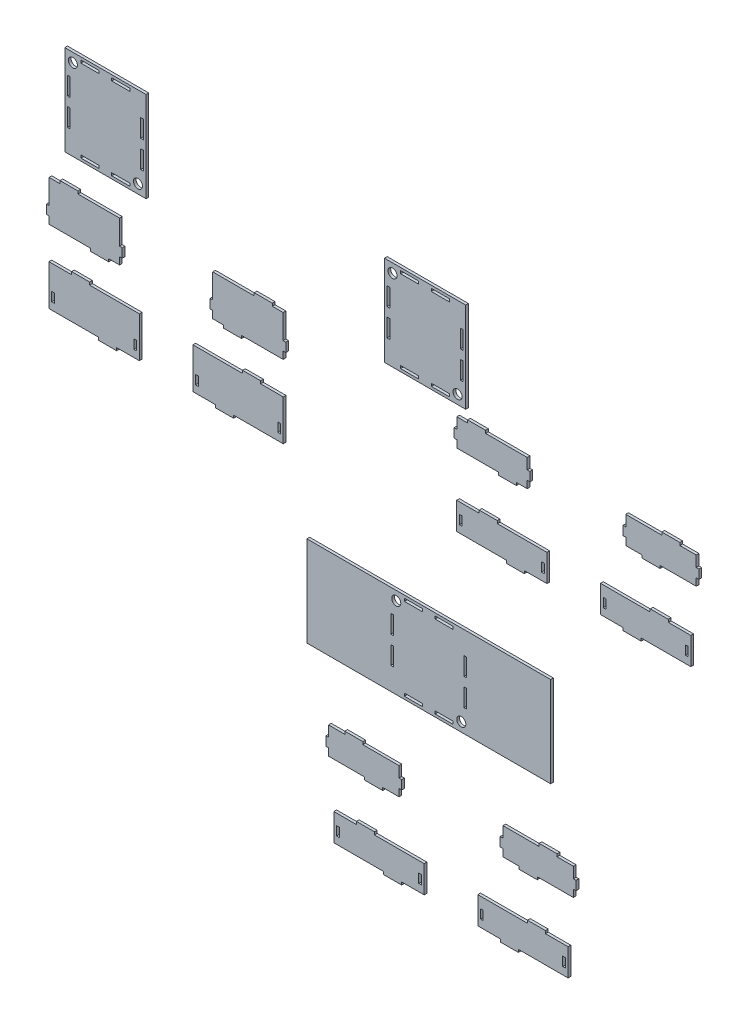
from build123d import *

# Parameters (mm, degrees)
EXTRUDE_1_DEPTH    = 3
SKETCH_1_W         = 3
SKETCH_1_H         = 10
EXTRUDE_1_2_DEPTH  = 3
EXTRUDE_1_3_DEPTH  = 3
SKETCH_1_W_2       = 90
SKETCH_1_H_2       = 100
SKETCH_1_R         = 5
SKETCH_1_H_3       = 20
SKETCH_1_W_3       = 20
SKETCH_1_H_4       = 3
EXTRUDE_1_4_DEPTH  = 3
EXTRUDE_1_5_DEPTH  = 3
EXTRUDE_1_6_DEPTH  = 3
EXTRUDE_1_7_DEPTH  = 3
EXTRUDE_1_8_DEPTH  = 3
EXTRUDE_1_9_DEPTH  = 3
EXTRUDE_1_10_DEPTH = 3
EXTRUDE_1_11_DEPTH = 3
EXTRUDE_1_12_DEPTH = 3
EXTRUDE_1_13_DEPTH = 3
EXTRUDE_1_14_DEPTH = 3
EXTRUDE_1_15_DEPTH = 3


with BuildPart() as part:
    # Эскиз1 → Бобышка-Вытянуть1 (new body)
    with BuildSketch(Plane.XY):
        Polygon((-251.165470976, 199.705049255), (-254.165470976, 199.705049255), (-254.165470976, 189.705049255), (-251.165470976, 189.705049255), (-251.165470976, 181.705049255), (-205.165470976, 181.705049255), (-205.165470976, 178.705049255), (-185.165470976, 178.705049255), (-185.165470976, 181.705049255), (-173.165470976, 181.705049255), (-173.165470976, 189.705049255), (-170.165470976, 189.705049255), (-170.165470976, 199.705049255), (-173.165470976, 199.705049255), (-173.165470976, 226.705049255), (-219.165470976, 226.705049255), (-219.165470976, 229.705049255), (-239.165470976, 229.705049255), (-239.165470976, 226.705049255), (-251.165470976, 226.705049255), align=None)
    extrude(amount=EXTRUDE_1_DEPTH)


with BuildPart() as body_2:
    # Эскиз1 → Extrude 1 2 (new body)
    with BuildSketch(Plane.XY):
        Polygon((-196.271811444, 100.833532478), (-196.271811444, 97.833532478), (-176.271811444, 97.833532478), (-176.271811444, 100.833532478), (-151.271811444, 100.833532478), (-151.271811444, 145.833532478), (-206.271811444, 145.833532478), (-206.271811444, 148.833532478), (-226.271811444, 148.833532478), (-226.271811444, 145.833532478), (-251.271811444, 145.833532478), (-251.271811444, 100.833532478), align=None)
        with Locations((-246.771811444, 113.833532478)):
            Rectangle(SKETCH_1_W, SKETCH_1_H, mode=Mode.SUBTRACT)
        with Locations((-155.771811444, 113.833532478)):
            Rectangle(SKETCH_1_W, SKETCH_1_H, mode=Mode.SUBTRACT)
    extrude(amount=EXTRUDE_1_2_DEPTH)


with BuildPart() as body_3:
    # Эскиз1 → Extrude 1 3 (new body)
    with BuildSketch(Plane.XY):
        Polygon((-58.028496911, 181.705049255), (-70.028496911, 181.705049255), (-70.028496911, 189.705049255), (-73.028496911, 189.705049255), (-73.028496911, 199.705049255), (-70.028496911, 199.705049255), (-70.028496911, 226.705049255), (-24.028496911, 226.705049255), (-24.028496911, 229.705049255), (-4.028496911, 229.705049255), (-4.028496911, 226.705049255), (7.971503089, 226.705049255), (7.971503089, 199.705049255), (10.971503089, 199.705049255), (10.971503089, 189.705049255), (7.971503089, 189.705049255), (7.971503089, 181.705049255), (-38.028496911, 181.705049255), (-38.028496911, 178.705049255), (-58.028496911, 178.705049255), align=None)
    extrude(amount=EXTRUDE_1_3_DEPTH)


with BuildPart() as body_4:
    # Эскиз1 → Extrude 1 4 (new body)
    with BuildSketch(Plane.XY):
        with Locations((-188.822696294, 309.879947413)):
            Rectangle(SKETCH_1_W_2, SKETCH_1_H_2)
        with Locations((-152.822696294, 269.879947413)):
            Circle(SKETCH_1_R, mode=Mode.SUBTRACT)
        with Locations((-224.822696294, 349.879947413)):
            Circle(SKETCH_1_R, mode=Mode.SUBTRACT)
        with Locations((-229.322696294, 294.879947413)):
            Rectangle(SKETCH_1_W, SKETCH_1_H_3, mode=Mode.SUBTRACT)
        with Locations((-205.822696294, 355.379947413)):
            Rectangle(SKETCH_1_W_3, SKETCH_1_H_4, mode=Mode.SUBTRACT)
        with Locations((-148.322696294, 294.879947413)):
            Rectangle(SKETCH_1_W, SKETCH_1_H_3, mode=Mode.SUBTRACT)
        with Locations((-205.822696294, 264.379947413)):
            Rectangle(SKETCH_1_W_3, SKETCH_1_H_4, mode=Mode.SUBTRACT)
        with Locations((-171.822696294, 355.379947413)):
            Rectangle(SKETCH_1_W_3, SKETCH_1_H_4, mode=Mode.SUBTRACT)
        with Locations((-148.322696294, 324.879947413)):
            Rectangle(SKETCH_1_W, SKETCH_1_H_3, mode=Mode.SUBTRACT)
        with Locations((-229.322696294, 324.879947413)):
            Rectangle(SKETCH_1_W, SKETCH_1_H_3, mode=Mode.SUBTRACT)
        with Locations((-171.822696294, 264.379947413)):
            Rectangle(SKETCH_1_W_3, SKETCH_1_H_4, mode=Mode.SUBTRACT)
    extrude(amount=EXTRUDE_1_4_DEPTH)


with BuildPart() as body_5:
    # Эскиз1 → Extrude 1 5 (new body)
    with BuildSketch(Plane.XY):
        Polygon((-36.922156443, 145.833532478), (-91.922156443, 145.833532478), (-91.922156443, 100.833532478), (-66.922156443, 100.833532478), (-66.922156443, 97.833532478), (-46.922156443, 97.833532478), (-46.922156443, 100.833532478), (8.077843557, 100.833532478), (8.077843557, 145.833532478), (-16.922156443, 145.833532478), (-16.922156443, 148.833532478), (-36.922156443, 148.833532478), align=None)
        with Locations((-87.422156443, 113.833532478)):
            Rectangle(SKETCH_1_W, SKETCH_1_H, mode=Mode.SUBTRACT)
        with Locations((3.577843557, 113.833532478)):
            Rectangle(SKETCH_1_W, SKETCH_1_H, mode=Mode.SUBTRACT)
    extrude(amount=EXTRUDE_1_5_DEPTH)


with BuildPart() as body_6:
    # Эскиз1 → Extrude 1 6 (new body)
    with BuildSketch(Plane.XY):
        with Locations((165.137211889, 284.937042664)):
            Rectangle(SKETCH_1_W_2, SKETCH_1_H_2)
        with Locations((201.137211889, 244.937042664)):
            Circle(SKETCH_1_R, mode=Mode.SUBTRACT)
        with Locations((129.137211889, 324.937042664)):
            Circle(SKETCH_1_R, mode=Mode.SUBTRACT)
        with Locations((124.637211889, 269.937042664)):
            Rectangle(SKETCH_1_W, SKETCH_1_H_3, mode=Mode.SUBTRACT)
        with Locations((148.137211889, 330.437042664)):
            Rectangle(SKETCH_1_W_3, SKETCH_1_H_4, mode=Mode.SUBTRACT)
        with Locations((205.637211889, 269.937042664)):
            Rectangle(SKETCH_1_W, SKETCH_1_H_3, mode=Mode.SUBTRACT)
        with Locations((148.137211889, 239.437042664)):
            Rectangle(SKETCH_1_W_3, SKETCH_1_H_4, mode=Mode.SUBTRACT)
        with Locations((182.137211889, 330.437042664)):
            Rectangle(SKETCH_1_W_3, SKETCH_1_H_4, mode=Mode.SUBTRACT)
        with Locations((205.637211889, 299.937042664)):
            Rectangle(SKETCH_1_W, SKETCH_1_H_3, mode=Mode.SUBTRACT)
        with Locations((124.637211889, 299.937042664)):
            Rectangle(SKETCH_1_W, SKETCH_1_H_3, mode=Mode.SUBTRACT)
        with Locations((182.137211889, 239.437042664)):
            Rectangle(SKETCH_1_W_3, SKETCH_1_H_4, mode=Mode.SUBTRACT)
    extrude(amount=EXTRUDE_1_6_DEPTH)


with BuildPart() as body_7:
    # Эскиз1 → Extrude 1 7 (new body)
    with BuildSketch(Plane.XY):
        Polygon((124.266684173, 22.861216451), (214.266684173, 22.861216451), (304.266684173, 22.861216451), (304.266684173, -77.138783549), (214.266684173, -77.138783549), (124.266684173, -77.138783549), (34.266684173, -77.138783549), (34.266684173, 22.861216451), align=None)
        with Locations((205.266684173, -67.138783549)):
            Circle(SKETCH_1_R, mode=Mode.SUBTRACT)
        with Locations((133.266684173, 12.861216451)):
            Circle(SKETCH_1_R, mode=Mode.SUBTRACT)
        with Locations((128.766684173, -42.138783549)):
            Rectangle(SKETCH_1_W, SKETCH_1_H_3, mode=Mode.SUBTRACT)
        with Locations((152.266684173, 18.361216451)):
            Rectangle(SKETCH_1_W_3, SKETCH_1_H_4, mode=Mode.SUBTRACT)
        with Locations((209.766684173, -42.138783549)):
            Rectangle(SKETCH_1_W, SKETCH_1_H_3, mode=Mode.SUBTRACT)
        with Locations((152.266684173, -72.638783549)):
            Rectangle(SKETCH_1_W_3, SKETCH_1_H_4, mode=Mode.SUBTRACT)
        with Locations((186.266684173, 18.361216451)):
            Rectangle(SKETCH_1_W_3, SKETCH_1_H_4, mode=Mode.SUBTRACT)
        with Locations((209.766684173, -12.138783549)):
            Rectangle(SKETCH_1_W, SKETCH_1_H_3, mode=Mode.SUBTRACT)
        with Locations((128.766684173, -12.138783549)):
            Rectangle(SKETCH_1_W, SKETCH_1_H_3, mode=Mode.SUBTRACT)
        with Locations((186.266684173, -72.638783549)):
            Rectangle(SKETCH_1_W_3, SKETCH_1_H_4, mode=Mode.SUBTRACT)
    extrude(amount=EXTRUDE_1_7_DEPTH)


with BuildPart() as body_8:
    # Эскиз1 → Extrude 1 8 (new body)
    with BuildSketch(Plane.XY):
        Polygon((200.250040897, 210.886801251), (197.250040897, 210.886801251), (197.250040897, 200.886801251), (200.250040897, 200.886801251), (200.250040897, 192.886801251), (246.250040897, 192.886801251), (246.250040897, 189.886801251), (266.250040897, 189.886801251), (266.250040897, 192.886801251), (278.250040897, 192.886801251), (278.250040897, 200.886801251), (281.250040897, 200.886801251), (281.250040897, 210.886801251), (278.250040897, 210.886801251), (278.250040897, 222.886801251), (232.250040897, 222.886801251), (232.250040897, 225.886801251), (212.250040897, 225.886801251), (212.250040897, 222.886801251), (200.250040897, 222.886801251), align=None)
    extrude(amount=EXTRUDE_1_8_DEPTH)


with BuildPart() as body_9:
    # Эскиз1 → Extrude 1 9 (new body)
    with BuildSketch(Plane.XY):
        Polygon((255.143700429, 112.775535577), (255.143700429, 109.775535577), (275.143700429, 109.775535577), (275.143700429, 112.775535577), (300.143700429, 112.775535577), (300.143700429, 142.775535577), (245.143700429, 142.775535577), (245.143700429, 145.775535577), (225.143700429, 145.775535577), (225.143700429, 142.775535577), (200.143700429, 142.775535577), (200.143700429, 112.775535577), align=None)
        with Locations((204.643700429, 125.775535577)):
            Rectangle(SKETCH_1_W, SKETCH_1_H, mode=Mode.SUBTRACT)
        with Locations((295.643700429, 125.775535577)):
            Rectangle(SKETCH_1_W, SKETCH_1_H, mode=Mode.SUBTRACT)
    extrude(amount=EXTRUDE_1_9_DEPTH)


with BuildPart() as body_10:
    # Эскиз1 → Extrude 1 10 (new body)
    with BuildSketch(Plane.XY):
        Polygon((405.387014962, 192.886801251), (387.387014962, 192.886801251), (387.387014962, 200.886801251), (384.387014962, 200.886801251), (384.387014962, 210.886801251), (387.387014962, 210.886801251), (387.387014962, 222.886801251), (427.387014962, 222.886801251), (427.387014962, 225.886801251), (447.387014962, 225.886801251), (447.387014962, 222.886801251), (465.387014962, 222.886801251), (465.387014962, 210.886801251), (468.387014962, 210.886801251), (468.387014962, 200.886801251), (465.387014962, 200.886801251), (465.387014962, 192.886801251), (425.387014962, 192.886801251), (425.387014962, 189.886801251), (405.387014962, 189.886801251), align=None)
    extrude(amount=EXTRUDE_1_10_DEPTH)


with BuildPart() as body_11:
    # Эскиз1 → Extrude 1 11 (new body)
    with BuildSketch(Plane.XY):
        Polygon((414.49335543, 142.775535577), (359.49335543, 142.775535577), (359.49335543, 112.775535577), (384.49335543, 112.775535577), (384.49335543, 109.775535577), (404.49335543, 109.775535577), (404.49335543, 112.775535577), (459.49335543, 112.775535577), (459.49335543, 142.775535577), (434.49335543, 142.775535577), (434.49335543, 145.775535577), (414.49335543, 145.775535577), align=None)
        with Locations((363.99335543, 125.775535577)):
            Rectangle(SKETCH_1_W, SKETCH_1_H, mode=Mode.SUBTRACT)
        with Locations((454.99335543, 125.775535577)):
            Rectangle(SKETCH_1_W, SKETCH_1_H, mode=Mode.SUBTRACT)
    extrude(amount=EXTRUDE_1_11_DEPTH)


with BuildPart() as body_12:
    # Эскиз1 → Extrude 1 12 (new body)
    with BuildSketch(Plane.XY):
        Polygon((58.2619165, -155.625503593), (55.2619165, -155.625503593), (55.2619165, -165.625503593), (58.2619165, -165.625503593), (58.2619165, -173.625503593), (98.2619165, -173.625503593), (98.2619165, -176.625503593), (118.2619165, -176.625503593), (118.2619165, -173.625503593), (136.2619165, -173.625503593), (136.2619165, -165.625503593), (139.2619165, -165.625503593), (139.2619165, -155.625503593), (136.2619165, -155.625503593), (136.2619165, -143.625503593), (96.2619165, -143.625503593), (96.2619165, -140.625503593), (76.2619165, -140.625503593), (76.2619165, -143.625503593), (58.2619165, -143.625503593), align=None)
    extrude(amount=EXTRUDE_1_12_DEPTH)


with BuildPart() as body_13:
    # Эскиз1 → Extrude 1 13 (new body)
    with BuildSketch(Plane.XY):
        Polygon((119.155576032, -253.736769267), (119.155576032, -256.736769267), (139.155576032, -256.736769267), (139.155576032, -253.736769267), (164.155576032, -253.736769267), (164.155576032, -223.736769267), (109.155576032, -223.736769267), (109.155576032, -220.736769267), (89.155576032, -220.736769267), (89.155576032, -223.736769267), (64.155576032, -223.736769267), (64.155576032, -253.736769267), align=None)
        with Locations((68.655576032, -240.736769267)):
            Rectangle(SKETCH_1_W, SKETCH_1_H, mode=Mode.SUBTRACT)
        with Locations((159.655576032, -240.736769267)):
            Rectangle(SKETCH_1_W, SKETCH_1_H, mode=Mode.SUBTRACT)
    extrude(amount=EXTRUDE_1_13_DEPTH)


with BuildPart() as body_14:
    # Эскиз1 → Extrude 1 14 (new body)
    with BuildSketch(Plane.XY):
        Polygon((269.398890565, -173.625503593), (251.398890565, -173.625503593), (251.398890565, -165.625503593), (248.398890565, -165.625503593), (248.398890565, -155.625503593), (251.398890565, -155.625503593), (251.398890565, -143.625503593), (291.398890565, -143.625503593), (291.398890565, -140.625503593), (311.398890565, -140.625503593), (311.398890565, -143.625503593), (329.398890565, -143.625503593), (329.398890565, -155.625503593), (332.398890565, -155.625503593), (332.398890565, -165.625503593), (329.398890565, -165.625503593), (329.398890565, -173.625503593), (289.398890565, -173.625503593), (289.398890565, -176.625503593), (269.398890565, -176.625503593), align=None)
    extrude(amount=EXTRUDE_1_14_DEPTH)


with BuildPart() as body_15:
    # Эскиз1 → Extrude 1 15 (new body)
    with BuildSketch(Plane.XY):
        Polygon((278.505231033, -223.736769267), (223.505231033, -223.736769267), (223.505231033, -253.736769267), (248.505231033, -253.736769267), (248.505231033, -256.736769267), (268.505231033, -256.736769267), (268.505231033, -253.736769267), (323.505231033, -253.736769267), (323.505231033, -223.736769267), (298.505231033, -223.736769267), (298.505231033, -220.736769267), (278.505231033, -220.736769267), align=None)
        with Locations((228.005231033, -240.736769267)):
            Rectangle(SKETCH_1_W, SKETCH_1_H, mode=Mode.SUBTRACT)
        with Locations((319.005231033, -240.736769267)):
            Rectangle(SKETCH_1_W, SKETCH_1_H, mode=Mode.SUBTRACT)
    extrude(amount=EXTRUDE_1_15_DEPTH)


solid = Compound([part.part, body_2.part, body_3.part, body_4.part, body_5.part, body_6.part, body_7.part, body_8.part, body_9.part, body_10.part, body_11.part, body_12.part, body_13.part, body_14.part, body_15.part])
